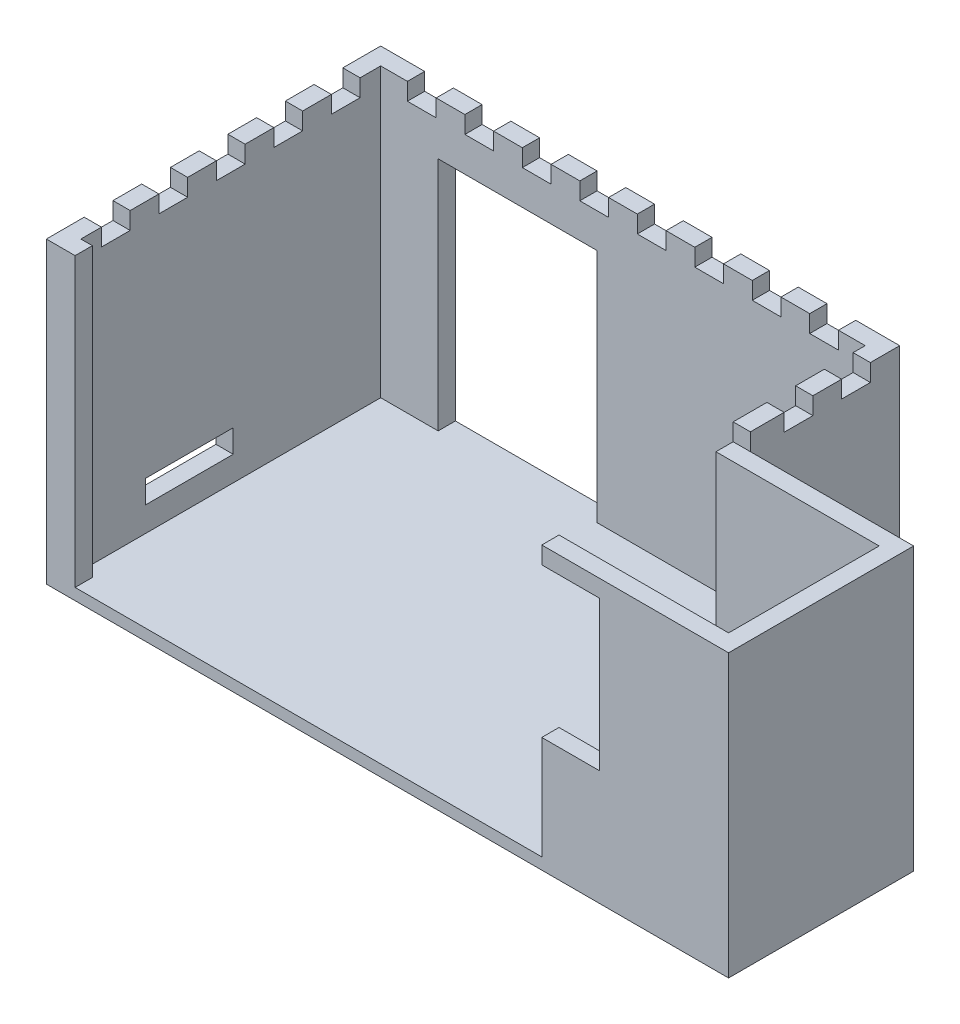
from build123d import *

# Parameters (mm, degrees)
SKETCH1_W           = 90.3
SKETCH1_H           = 58.17
BOSS_EXTRUDE1_DEPTH = 2
SKETCH4_W           = 28.4
SKETCH4_H           = 32.2
BOSS_EXTRUDE2_DEPTH = 2
BOSS_EXTRUDE3_DEPTH = 20
SKETCH6_W           = 3
SKETCH6_H           = 58.17
BOSS_EXTRUDE4_DEPTH = 50
SKETCH7_W           = 15.3
SKETCH7_H           = 4
CUT_EXTRUDE1_DEPTH  = 4
SKETCH8_W           = 10
SKETCH8_H           = 3
SKETCH8_W_2         = 22
BOSS_EXTRUDE5_DEPTH = 50
SKETCH9_W           = 3
SKETCH9_H           = 9
BOSS_EXTRUDE7_DEPTH = 30
BOSS_EXTRUDE8_DEPTH = 30
SKETCH11_W          = 2
SKETCH11_H          = 3
BOSS_EXTRUDE9_DEPTH = 50
SKETCH12_W          = 10
SKETCH12_H          = 26
CUT_EXTRUDE2_DEPTH  = 5
SKETCH13_W          = 3
SKETCH13_H          = 5
SKETCH13_W_2        = 5
SKETCH13_H_2        = 3
SKETCH13_W_3        = 32.5
SKETCH13_H_3        = 32.2
CUT_EXTRUDE3_DEPTH  = 3


with BuildPart() as part:
    # Sketch1 → Boss-Extrude1 (new body)
    with BuildSketch(Plane(origin=(0, 0, 0), x_dir=(1, 0, 0), z_dir=(0, 1, 0))):
        with Locations((8.649006711, -3.245187919)):
            Rectangle(SKETCH1_W, SKETCH1_H)
    extrude(amount=BOSS_EXTRUDE1_DEPTH)

    # Sketch4 → Boss-Extrude2 (add)
    with BuildSketch(Plane(origin=(0, 2, 0), x_dir=(1, 0, 0), z_dir=(0, 1, 0))):
        with Locations((67.999006711, -16.230187919)):
            Rectangle(SKETCH4_W, SKETCH4_H)
    extrude(amount=-BOSS_EXTRUDE2_DEPTH)

    # Sketch5 → Boss-Extrude3 (add)
    with BuildSketch(Plane(origin=(0, 2, 0), x_dir=(1, 0, 0), z_dir=(0, 1, 0))):
        Polygon((82.199006711, -0.130187919), (82.199006711, -32.330187919), (49.699006711, -32.330187919), (49.699006711, -29.330187919), (79.199006711, -29.330187919), (79.199006711, -3.130187919), (50.799006711, -3.130187919), (50.799006711, 22.839812081), (26.155250354, 22.839812081), (26.155250354, 25.839812081), (53.799006711, 25.839812081), (53.799006711, -0.130187919), align=None)
    extrude(amount=BOSS_EXTRUDE3_DEPTH)

    # Sketch6 → Boss-Extrude4 (add)
    with BuildSketch(Plane(origin=(0, 2, 0), x_dir=(1, 0, 0), z_dir=(0, 1, 0))):
        with Locations((-35.000993289, -3.245187919)):
            Rectangle(SKETCH6_W, SKETCH6_H)
    extrude(amount=BOSS_EXTRUDE4_DEPTH)

    # Sketch7 → Cut-Extrude1 (cut)
    with BuildSketch(Plane.ZY.offset(36.500993289)):
        with Locations((10.470187919, 8.31)):
            Rectangle(SKETCH7_W, SKETCH7_H)
    extrude(amount=-CUT_EXTRUDE1_DEPTH, mode=Mode.SUBTRACT)

    # Sketch8 → Boss-Extrude5 (add)
    with BuildSketch(Plane(origin=(0, 2, 0), x_dir=(1, 0, 0), z_dir=(0, 1, 0))):
        with Locations((-28.500993289, 24.339812081)):
            Rectangle(SKETCH8_W, SKETCH8_H)
        with Locations((15.155250354, 24.339812081)):
            Rectangle(SKETCH8_W_2, SKETCH8_H)
    extrude(amount=BOSS_EXTRUDE5_DEPTH)

    # Sketch9 → Boss-Extrude7 (add)
    with BuildSketch(Plane.ZY.offset(-4.155250354)):
        with Locations((-24.339812081, 47.5)):
            Rectangle(SKETCH9_W, SKETCH9_H)
    extrude(amount=BOSS_EXTRUDE7_DEPTH)

    # Sketch10 → Boss-Extrude8 (add)
    with BuildSketch(Plane(origin=(0, 22, 0), x_dir=(1, 0, 0), z_dir=(0, 1, 0))):
        Polygon((26.155250354, 25.839812081), (26.155250354, 22.839812081), (50.799006711, 22.839812081), (50.799006711, -3.130187919), (79.199006711, -3.130187919), (79.199006711, -29.330187919), (49.699006711, -29.330187919), (49.699006711, -32.330187919), (82.199006711, -32.330187919), (82.199006711, -0.130187919), (53.799006711, -0.130187919), (53.799006711, 25.839812081), align=None)
    extrude(amount=BOSS_EXTRUDE8_DEPTH)

    # Sketch11 → Boss-Extrude9 (add)
    with BuildSketch(Plane(origin=(0, 2, 0), x_dir=(1, 0, 0), z_dir=(0, 1, 0))):
        with Locations((-32.500993289, -30.830187919)):
            Rectangle(SKETCH11_W, SKETCH11_H)
    extrude(amount=BOSS_EXTRUDE9_DEPTH)

    # Sketch12 → Cut-Extrude2 (cut)
    with BuildSketch(Plane.XY.offset(32.330187919)):
        with Locations((54.699006711, 33)):
            Rectangle(SKETCH12_W, SKETCH12_H)
    extrude(amount=-CUT_EXTRUDE2_DEPTH, mode=Mode.SUBTRACT)

    # Sketch13 → Cut-Extrude3 (cut)
    with BuildSketch(Plane(origin=(0, 52, 0), x_dir=(1, 0, 0), z_dir=(0, 1, 0))):
        with Locations((-35.000993289, -23.245187919)):
            Rectangle(SKETCH13_W, SKETCH13_H)
        with Locations((-35.000993289, -13.245187919)):
            Rectangle(SKETCH13_W, SKETCH13_H)
        with Locations((-35.000993289, -3.245187919)):
            Rectangle(SKETCH13_W, SKETCH13_H)
        with Locations((-35.000993289, 6.754812081)):
            Rectangle(SKETCH13_W, SKETCH13_H)
        with Locations((-35.000993289, 16.754812081)):
            Rectangle(SKETCH13_W, SKETCH13_H)
        with Locations((-26.350993289, 24.339812081)):
            Rectangle(SKETCH13_W_2, SKETCH13_H_2)
        with Locations((-16.350993289, 24.339812081)):
            Rectangle(SKETCH13_W_2, SKETCH13_H_2)
        with Locations((-6.350993289, 24.339812081)):
            Rectangle(SKETCH13_W_2, SKETCH13_H_2)
        with Locations((3.649006711, 24.339812081)):
            Rectangle(SKETCH13_W_2, SKETCH13_H_2)
        with Locations((13.649006711, 24.339812081)):
            Rectangle(SKETCH13_W_2, SKETCH13_H_2)
        with Locations((23.649006711, 24.339812081)):
            Rectangle(SKETCH13_W_2, SKETCH13_H_2)
        with Locations((33.649006711, 24.339812081)):
            Rectangle(SKETCH13_W_2, SKETCH13_H_2)
        with Locations((43.649006711, 24.339812081)):
            Rectangle(SKETCH13_W_2, SKETCH13_H_2)
        with Locations((65.949006711, -16.230187919)):
            Rectangle(SKETCH13_W_3, SKETCH13_H_3)
        with Locations((52.299006711, 18.239812081)):
            Rectangle(SKETCH13_W, SKETCH13_H)
        with Locations((52.299006711, 8.239812081)):
            Rectangle(SKETCH13_W, SKETCH13_H)
    extrude(amount=-CUT_EXTRUDE3_DEPTH, mode=Mode.SUBTRACT)


solid = part.part
